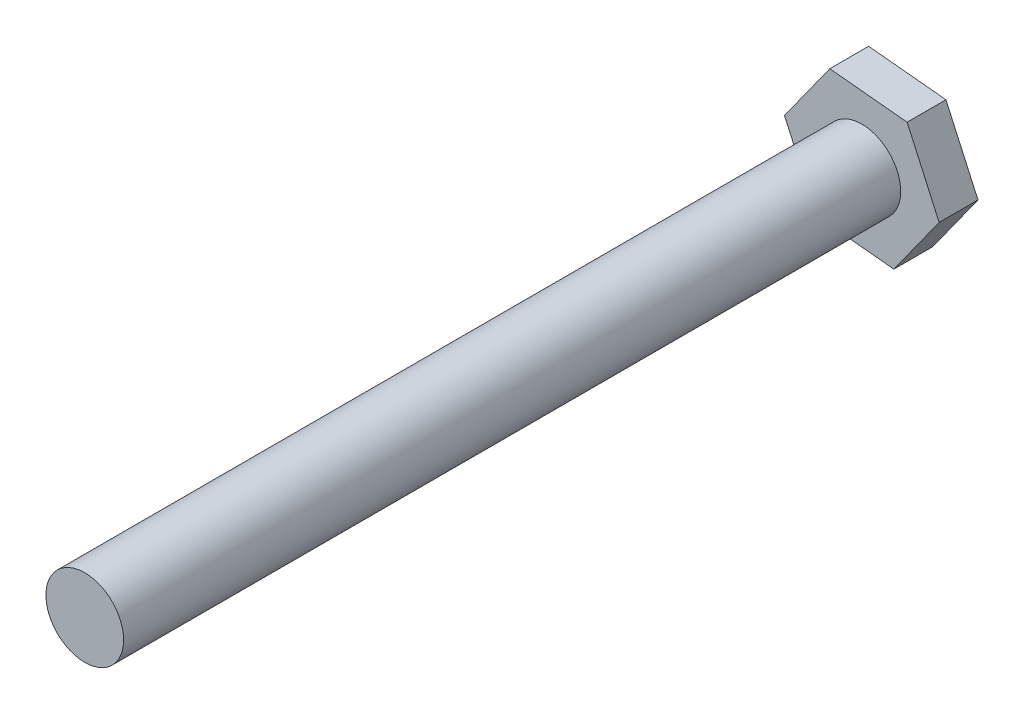
from build123d import *

# Parameters (mm, degrees)
BOSS_EXTRUDE1_DEPTH = 3
SKETCH2_R           = 3
BOSS_EXTRUDE2_DEPTH = 60


with BuildPart() as part:
    # Sketch1 → Boss-Extrude1 (new body)
    with BuildSketch(Plane.XY):
        Polygon((3.496740354, 4.875736549), (-2.474141537, 5.466134251), (-5.970881891, 0.590397702), (-3.496740354, -4.875736549), (2.474141537, -5.466134251), (5.970881891, -0.590397702), align=None)
    extrude(amount=BOSS_EXTRUDE1_DEPTH)

    # Sketch2 → Boss-Extrude2 (add)
    with BuildSketch(Plane.XY.offset(3)):
        Circle(SKETCH2_R)
    extrude(amount=BOSS_EXTRUDE2_DEPTH)


solid = part.part
